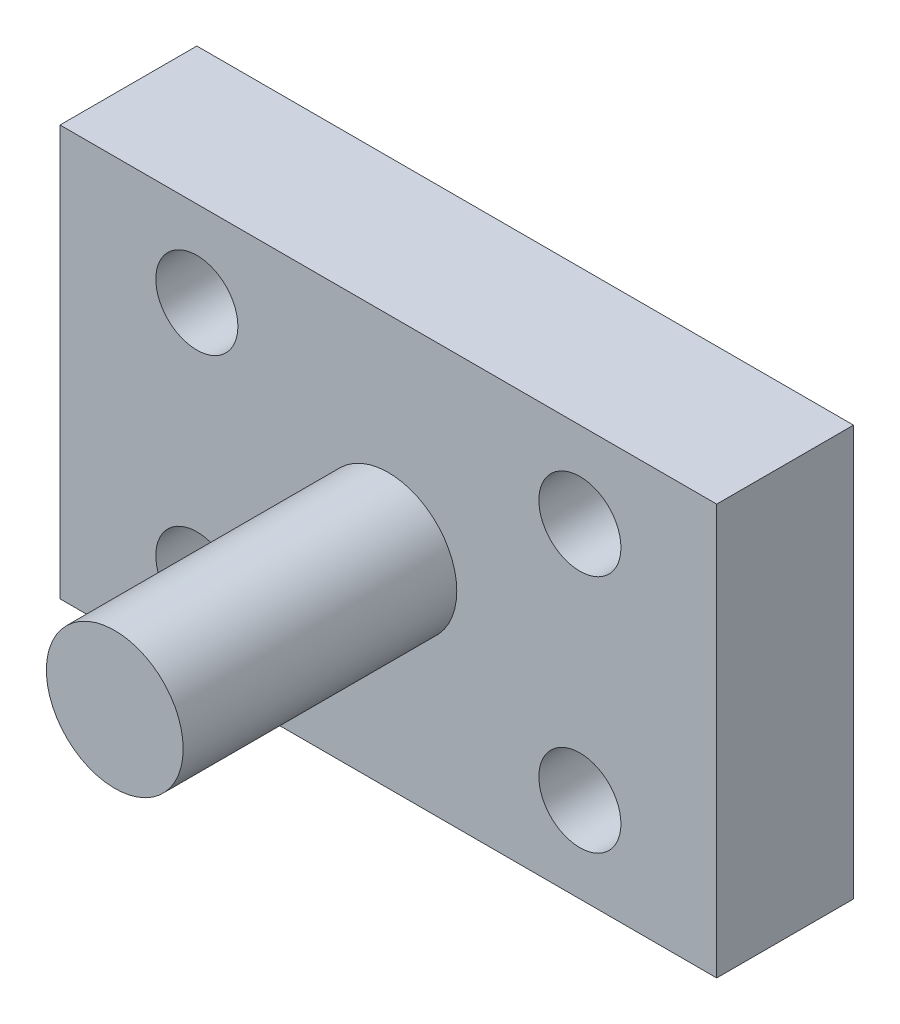
from build123d import *

# Parameters (mm, degrees)
SKETCH1_W           = 120
SKETCH1_H           = 75
SKETCH1_R           = 7.5
BOSS_EXTRUDE1_DEPTH = 25
SKETCH2_R           = 12.5
BOSS_EXTRUDE2_DEPTH = 50


with BuildPart() as part:
    # Sketch1 → Boss-Extrude1 (new body)
    with BuildSketch(Plane.XY):
        Rectangle(SKETCH1_W, SKETCH1_H)
        with Locations((35, 21.875)):
            Circle(SKETCH1_R, mode=Mode.SUBTRACT)
        with Locations((-35, 21.875)):
            Circle(SKETCH1_R, mode=Mode.SUBTRACT)
        with Locations((-35, -21.875)):
            Circle(SKETCH1_R, mode=Mode.SUBTRACT)
        with Locations((35, -21.875)):
            Circle(SKETCH1_R, mode=Mode.SUBTRACT)
    extrude(amount=BOSS_EXTRUDE1_DEPTH)

    # Sketch2 → Boss-Extrude2 (add)
    with BuildSketch(Plane.XY.offset(25)):
        Circle(SKETCH2_R)
    extrude(amount=BOSS_EXTRUDE2_DEPTH)


solid = part.part
